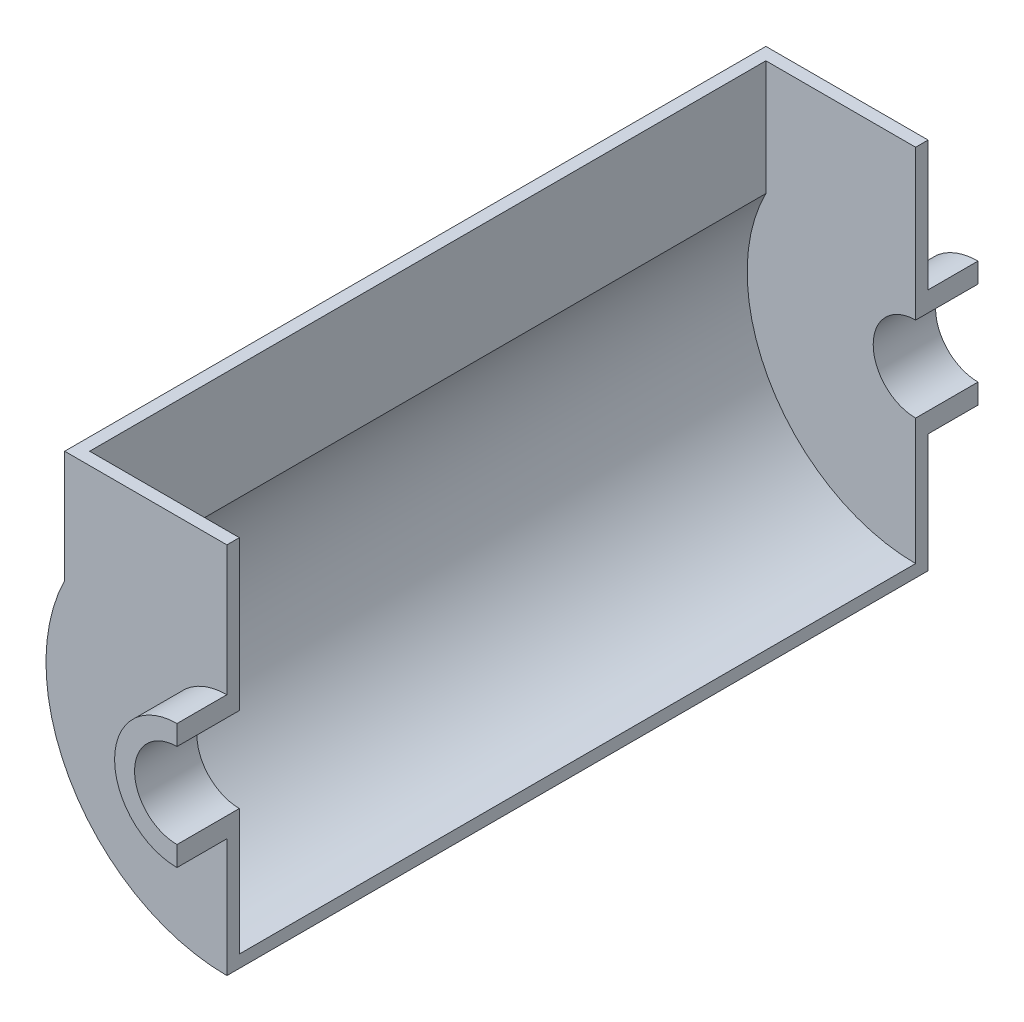
from build123d import *

# Parameters (mm, degrees)
BOSS_EXTRUDE1_DEPTH      = 20
BOSS_EXTRUDE1_DEPTH_BACK = 5
BOSS_EXTRUDE2_DEPTH      = 5
BOSS_EXTRUDE3_DEPTH      = 271


with BuildPart() as part:
    # Sketch1 → Boss-Extrude1 (new body, two sides)
    with BuildSketch(Plane.XY) as boss_extrude1_sk:
        with BuildLine():
            Line((0, 25), (0, 17))
            ThreePointArc((0, 17), (-17, 0), (0, -17))
            Line((0, -17), (0, -25))
            ThreePointArc((0, -25), (-25, 0), (0, 25))
        make_face()
    extrude(amount=BOSS_EXTRUDE1_DEPTH)
    extrude(boss_extrude1_sk.sketch, amount=-BOSS_EXTRUDE1_DEPTH_BACK)

    # Sketch2 → Boss-Extrude2 (add)
    with BuildSketch(Plane.XY):
        with BuildLine():
            Line((0, 25), (0, 77))
            Line((0, 77), (-65, 77))
            Line((-65, 77), (-65, 32.113081447))
            ThreePointArc((-65, 32.113081447), (-61.581037686, -38.262590053), (0, -72.5))
            Line((0, -72.5), (0, -25))
            ThreePointArc((0, -25), (-25, 0), (0, 25))
        make_face()
    extrude(amount=-BOSS_EXTRUDE2_DEPTH)


with BuildPart() as body_2:
    # Mirror12: mirrored copy
    add(part.part.mirror(Plane.XY.offset(-140.5)))


with BuildPart() as part_1:
    add(part.part)

    add(body_2.part)  # Boss-Extrude3 merges body 2
    # Sketch3 → Boss-Extrude3 (add)
    with BuildSketch(Plane(origin=(0, 0, -5), x_dir=(-1, 0, 0), z_dir=(0, 0, -1))):
        with BuildLine():
            Line((65, 77), (65, 32.113081447))
            ThreePointArc((65, 32.113081447), (61.581037686, -38.262590053), (0, -72.5))
            Line((0, -72.5), (0, -67.5))
            ThreePointArc((0, -67.5), (57.634938288, -35.134938288), (60, 30.923292192))
            Line((60, 30.923292192), (60, 77))
            Line((60, 77), (65, 77))
        make_face()
    extrude(amount=BOSS_EXTRUDE3_DEPTH)


solid = part_1.part
